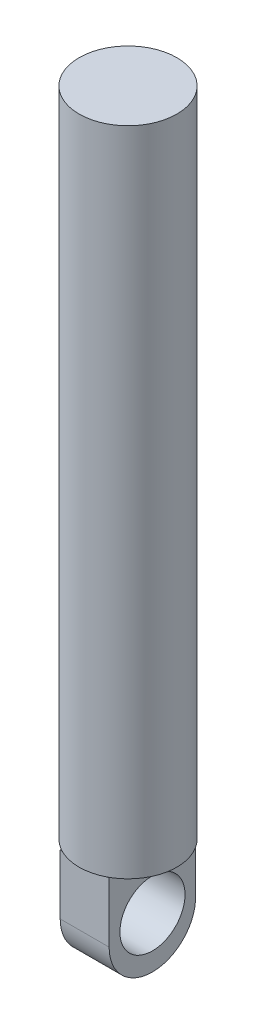
from build123d import *

# Parameters (mm, degrees)
SKETCH5_R           = 14.989713258
BOSS_EXTRUDE3_DEPTH = 200
BOSS_EXTRUDE4_DEPTH = 7.5
SKETCH7_R           = 9.985206203
CUT_EXTRUDE2_DEPTH  = 20


with BuildPart() as part:
    # Sketch5 → Boss-Extrude3 (new body)
    with BuildSketch(Plane(origin=(0, 0, 0), x_dir=(1, 0, 0), z_dir=(0, 1, 0))):
        Circle(SKETCH5_R)
    extrude(amount=BOSS_EXTRUDE3_DEPTH)

    # Sketch6 → Boss-Extrude4 (add, symmetric)
    with BuildSketch(Plane(origin=(0, 0, 0), x_dir=(0, -1, 0), z_dir=(-1, 0, 0))):
        with BuildLine():
            Line((0, 13.292901933), (18.33265387, 13.292901933))
            ThreePointArc((18.33265387, 13.292901933), (31.584492176, -0.298051084), (17.663099627, -13.202315957))
            Line((17.663099627, -13.202315957), (0, -13.202315957))
            Line((0, -13.202315957), (0, 13.292901933))
        make_face()
    extrude(amount=BOSS_EXTRUDE4_DEPTH, both=True)

    # Sketch7 → Cut-Extrude2 (cut, symmetric)
    with BuildSketch(Plane(origin=(7.5, 0, 0), x_dir=(0, 0, -1), z_dir=(1, 0, 0))):
        with Locations((0, -15.988279057)):
            Circle(SKETCH7_R)
    extrude(amount=CUT_EXTRUDE2_DEPTH, both=True, mode=Mode.SUBTRACT)


solid = part.part
